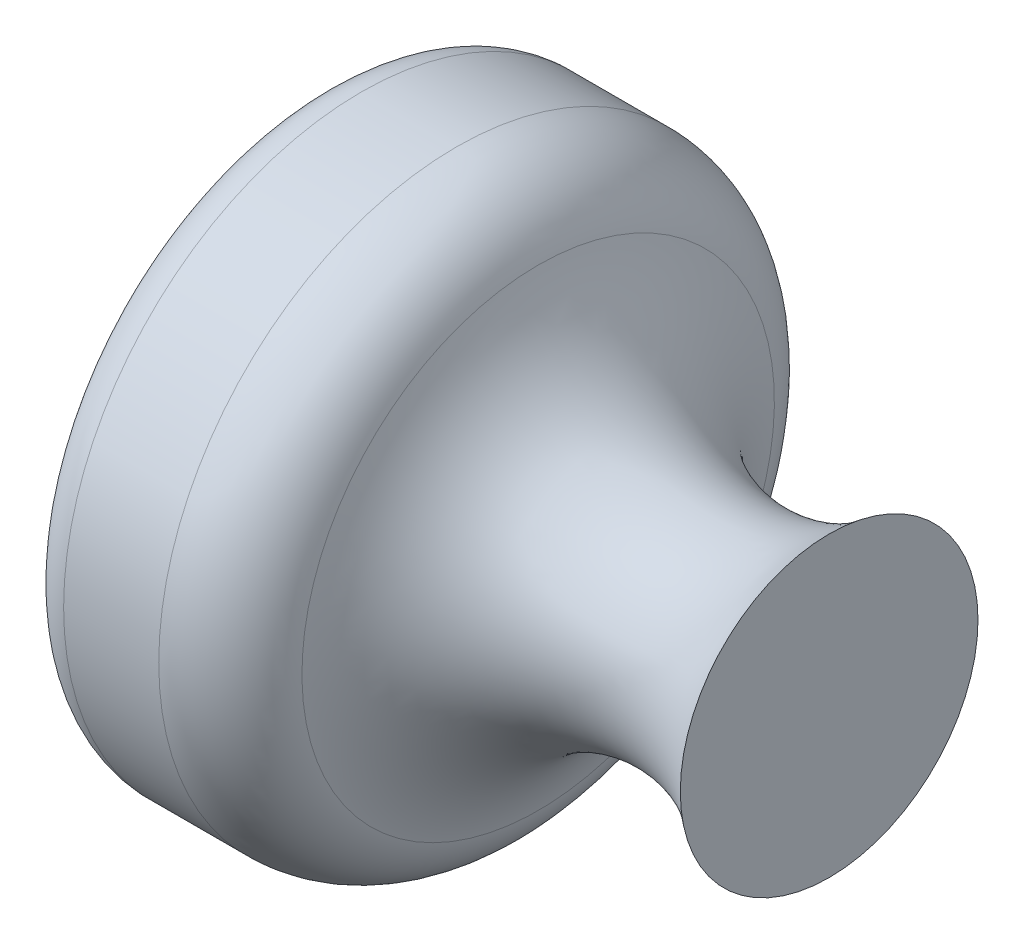
from build123d import *


with BuildPart() as part:
    # Sketch1 → Revolve1 (revolve)
    with BuildSketch(Plane.XY):
        with BuildLine():
            Line((-12, 0), (-12, 6))
            ThreePointArc((-12, 6), (-11.707106781, 6.707106781), (-11, 7))
            Line((-11, 7), (-8.763243193, 7))
            ThreePointArc((-8.763243193, 7), (-7.561010563, 6.598323091), (-6.84168702, 5.554636703))
            ThreePointArc((-6.84168702, 5.554636703), (-3.980771536, 2.662827028), (0, 3.5))
            Line((0, 3.5), (0, 0))
            Line((0, 0), (-12, 0))
        make_face()
    revolve(axis=Axis((0, 0, 0), (-1, 0, 0)))


solid = part.part
